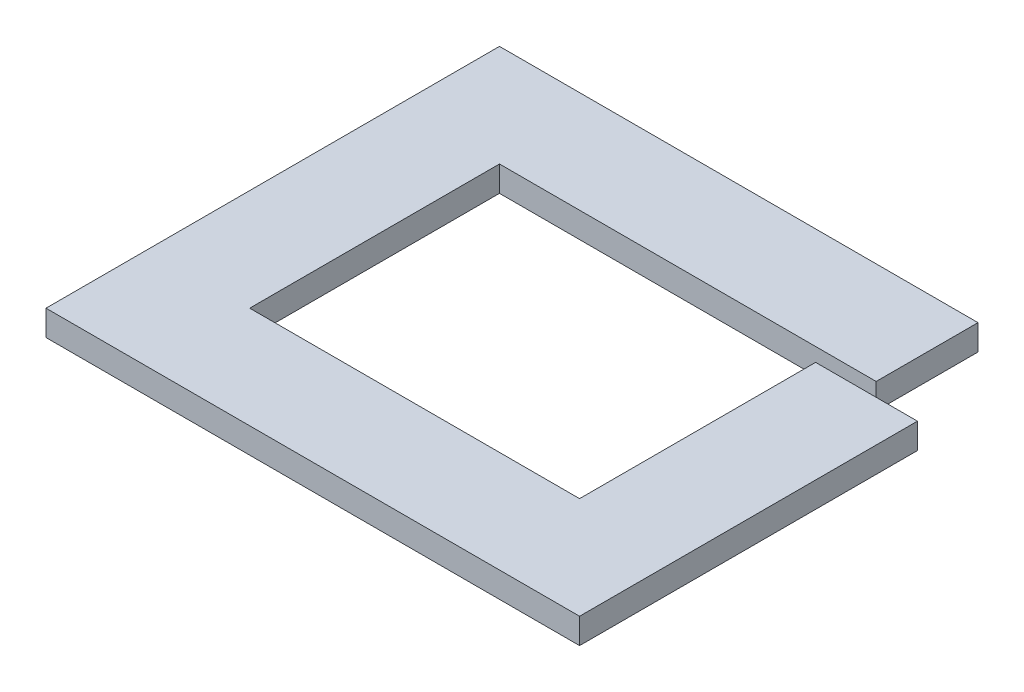
from build123d import *

# Parameters (mm, degrees)
BOSS_EXTRUDE1_START = 550
SKETCH1_W           = 80
SKETCH1_H           = 276.203950277
SKETCH1_W_2         = 295.879209743
SKETCH1_H_2         = 80
SKETCH1_H_3         = 12.7
BOSS_EXTRUDE1_DEPTH = 20


with BuildPart() as part:
    # Sketch1 → Boss-Extrude1 (new body)
    with BuildSketch(Plane(origin=(0, 5294.457128547, 0), x_dir=(1, 0, 0), z_dir=(0, 1, 0)).offset(BOSS_EXTRUDE1_START)):
        with Locations((-23153.790093454, -40062.769337853)):
            Rectangle(SKETCH1_W, SKETCH1_H)
        Polygon((-23113.790093454, -40200.871312991), (-23193.790093454, -40200.871312991), (-23193.790093454, -40280.871312991), (-22854.669978064, -40280.871312991), (-22854.669978064, -40200.871312991), align=None)
        Polygon((-22854.669978064, -40028.167362714), (-22854.669978064, -40200.871312991), (-22854.669978064, -40280.871312991), (-22774.669978064, -40280.871312991), (-22774.669978064, -40028.167362714), align=None)
        with Locations((-22965.850488583, -39964.667362714)):
            Rectangle(SKETCH1_W_2, SKETCH1_H_2)
        with Locations((-22814.669978064, -40021.817362714)):
            Rectangle(SKETCH1_W, SKETCH1_H_3)
    extrude(amount=BOSS_EXTRUDE1_DEPTH)


solid = part.part
